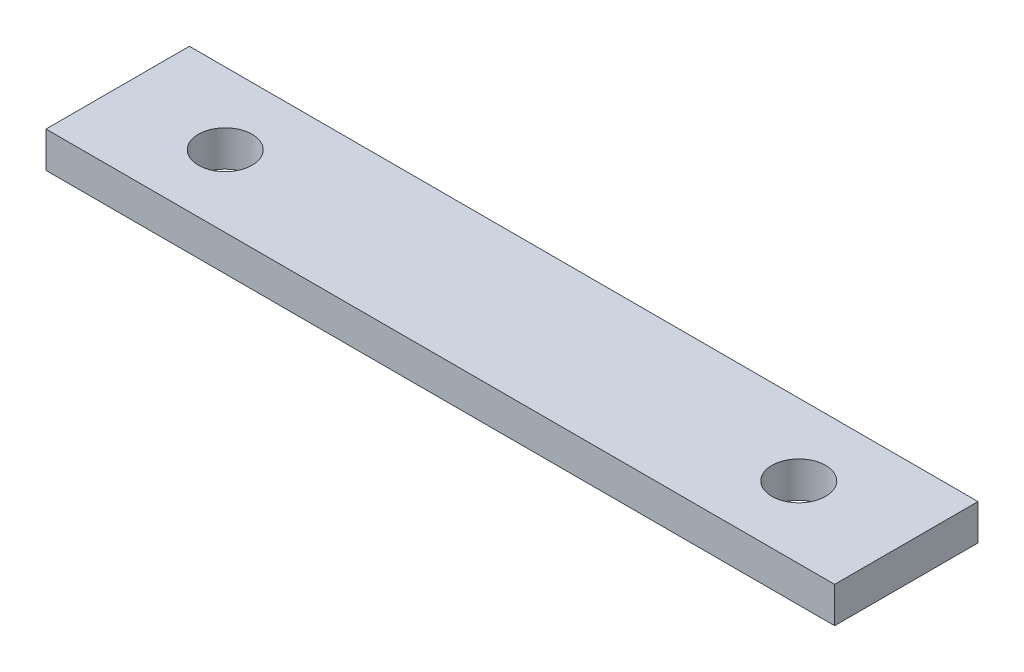
from build123d import *

# Parameters (mm, degrees)
SKETCH1_W           = 139.7
SKETCH1_H           = 25.4
BOSS_EXTRUDE1_DEPTH = 3.175
SKETCH2_R           = 4.7625
CUT_EXTRUDE1_DEPTH  = 7.35


with BuildPart() as part:
    # Sketch1 → Boss-Extrude1 (new body, symmetric)
    with BuildSketch(Plane(origin=(0, 0, 0), x_dir=(1, 0, 0), z_dir=(0, 1, 0))):
        Rectangle(SKETCH1_W, SKETCH1_H)
    extrude(amount=BOSS_EXTRUDE1_DEPTH, both=True)

    # Sketch2 → Cut-Extrude1 (cut, through all)
    with BuildSketch(Plane(origin=(0, 3.175, 0), x_dir=(1, 0, 0), z_dir=(0, 1, 0))):
        with Locations((50.8, 0)):
            Circle(SKETCH2_R)
        with Locations((-50.8, 0)):
            Circle(SKETCH2_R)
    extrude(amount=-CUT_EXTRUDE1_DEPTH, mode=Mode.SUBTRACT)


solid = part.part
